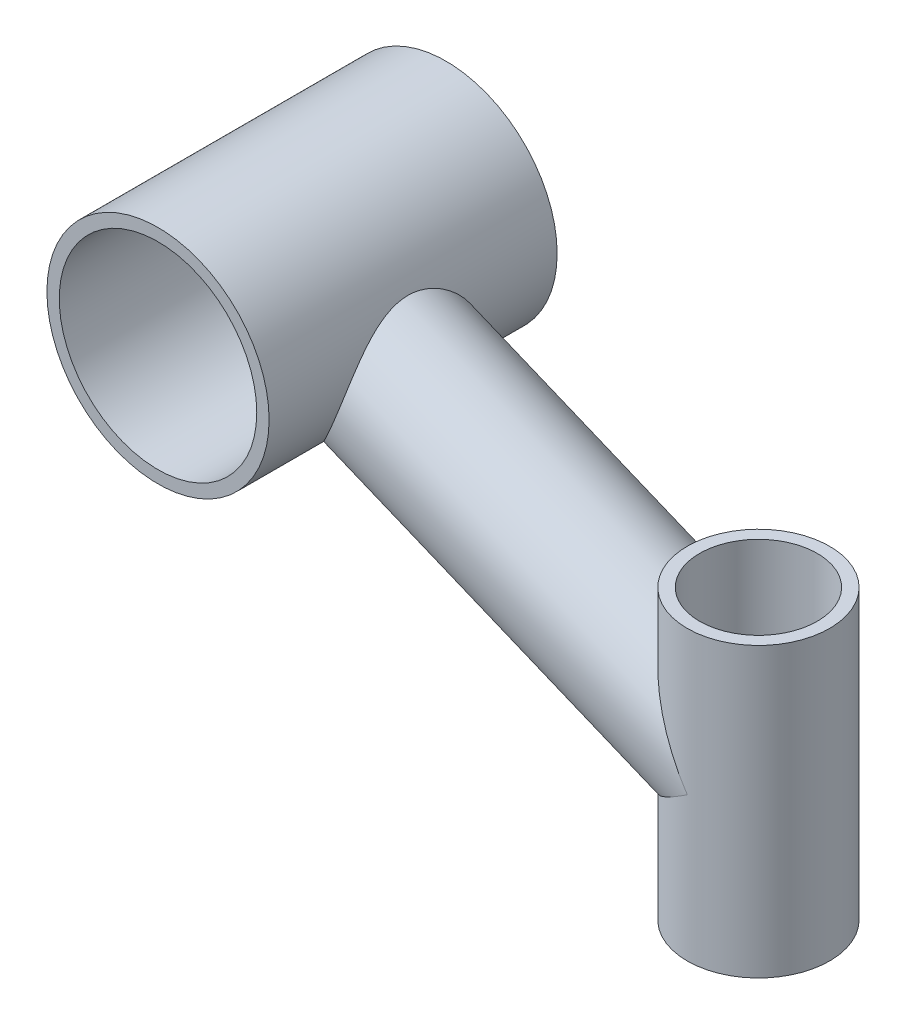
from build123d import *

# Parameters (mm, degrees)
ESQUISSE1_R                         = 27
ESQUISSE1_R_2                       = 24
ESQUISSE5_R                         = 17.3
ESQUISSE5_R_2                       = 14.3
BOSS_EXTRU_1_REACH                  = 108.661
BOSS_EXTRU_1_END_RADIUS             = 17.3
ESQUISSE8_R                         = 17.3
ESQUISSE8_R_2                       = 14.3
BOSS_EXTRU_1_DIRECTION_2_REACH      = 108.661
BOSS_EXTRU_1_DIRECTION_2_END_RADIUS = 27


with BuildPart() as part:
    # Balayage1: sweep along a path in Esquisse2
    with BuildLine(Plane(origin=(0, 0, 0), x_dir=(0, 0, -1), z_dir=(1, 0, 0))) as balayage1_path:
        Line((-35, 0), (35, 0))
    # Esquisse1 → Balayage1 (sweep)
    with BuildSketch(Plane.XY):
        Circle(ESQUISSE1_R)
        Circle(ESQUISSE1_R_2, mode=Mode.SUBTRACT)
    sweep(path=balayage1_path.line)



with BuildPart() as body_2:
    # Balayage2: sweep along a path in Esquisse6
    with BuildLine(Plane.XY) as balayage2_path:
        Line((110.918298302, -80.794444006), (110.918298302, -10.794444006))
    # Esquisse5 → Balayage2 (sweep)
    with BuildSketch(Plane(origin=(0, -45.794444006, 0), x_dir=(1, 0, 0), z_dir=(0, 1, 0))):
        with Locations((110.918298302, 0)):
            Circle(ESQUISSE5_R)
        with Locations((110.918298302, 0)):
            Circle(ESQUISSE5_R_2, mode=Mode.SUBTRACT)
    sweep(path=balayage2_path.line)


with BuildPart() as part_1:
    add(part.part)

    add(body_2.part)  # Boss.-Extru.1 merges body 2
    # Boss.-Extru.1: up to this cylinder (the profile starts outside it)
    boss_extru_1_end = Plane(origin=(110.918298302, -38.435657, 0), z_dir=(0, -1, 0)) * Cylinder(BOSS_EXTRU_1_END_RADIUS, 252.922, mode=Mode.PRIVATE)
    # Esquisse8 → Boss.-Extru.1 (add, up to the surface)
    with BuildSketch(Plane(origin=(55.459149151, -22.897222003, 0), x_dir=(0, 0, -1), z_dir=(0.9243191525163077, -0.381620366714795, 0)), mode=Mode.PRIVATE) as boss_extru_1_sk1:
        with Locations(Location((0, 0, 0), (0, 0, 90))):
            Circle(ESQUISSE8_R)
        with Locations(Location((0, 0, 0), (0, 0, 90))):
            Circle(ESQUISSE8_R_2, mode=Mode.SUBTRACT)
    boss_extru_1_tool1 = extrude(boss_extru_1_sk1.sketch, amount=BOSS_EXTRU_1_REACH, mode=Mode.PRIVATE) - boss_extru_1_end
    add(boss_extru_1_tool1.solids().sort_by_distance((49.04385, -38.435657, 0))[0])

    # Boss.-Extru.1 direction 2: up to this cylinder (the profile starts outside it)
    boss_extru_1_direction_2_end = Plane(origin=(0, 0, 0), z_dir=(0, 0, 1)) * Cylinder(BOSS_EXTRU_1_DIRECTION_2_END_RADIUS, 272.322, mode=Mode.PRIVATE)
    # Esquisse8 → Boss.-Extru.1 direction 2 (add, up to the surface)
    with BuildSketch(Plane(origin=(55.459149151, -22.897222003, 0), x_dir=(0, 0, -1), z_dir=(0.9243191525163077, -0.381620366714795, 0)), mode=Mode.PRIVATE) as boss_extru_1_direction_2_sk1:
        with Locations(Location((0, 0, 0), (0, 0, 90))):
            Circle(ESQUISSE8_R)
        with Locations(Location((0, 0, 0), (0, 0, 90))):
            Circle(ESQUISSE8_R_2, mode=Mode.SUBTRACT)
    boss_extru_1_direction_2_tool1 = extrude(boss_extru_1_direction_2_sk1.sketch, amount=-BOSS_EXTRU_1_DIRECTION_2_REACH, mode=Mode.PRIVATE) - boss_extru_1_direction_2_end
    add(boss_extru_1_direction_2_tool1.solids().sort_by_distance((49.04385, -38.435657, 0))[0])


solid = part_1.part
